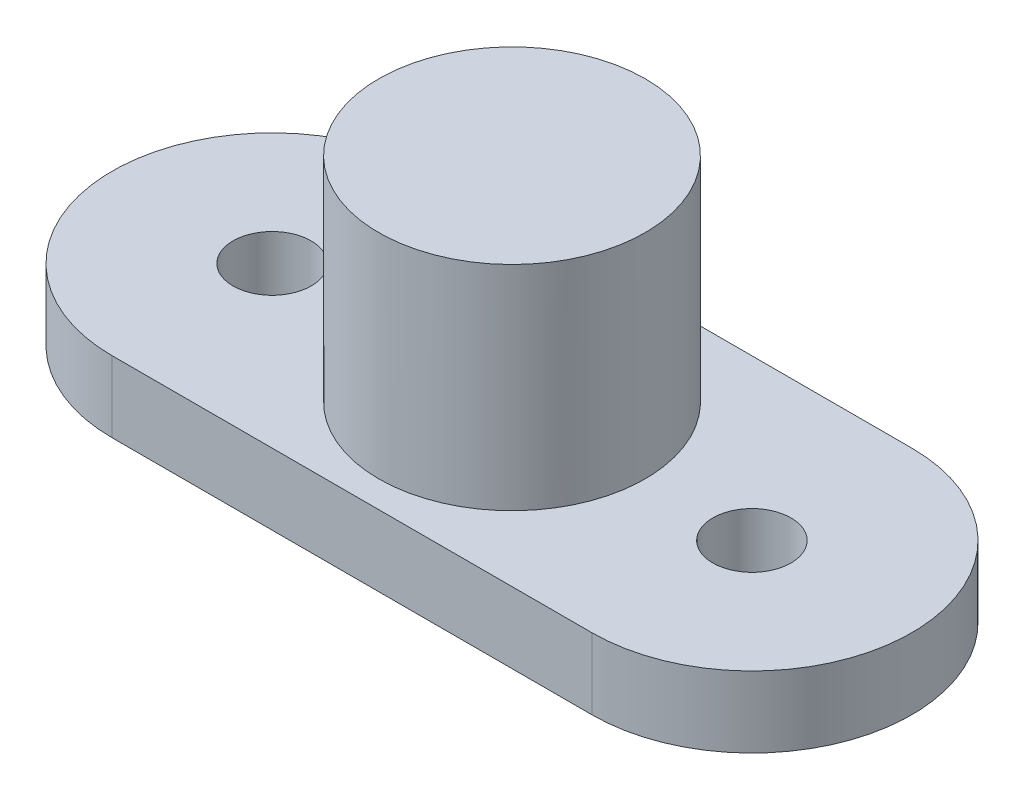
from build123d import *

# Parameters (mm, degrees)
SKETCH1_R           = 1.1
SKETCH1_R_2         = 3.75
BOSS_EXTRUDE3_DEPTH = 2
SKETCH3_R           = 3.75
BOSS_EXTRUDE4_DEPTH = 8


with BuildPart() as part:
    # Sketch1 → Boss-Extrude3 (new body)
    with BuildSketch(Plane(origin=(0, 0, 0), x_dir=(1, 0, 0), z_dir=(0, 1, 0))):
        with BuildLine():
            Line((-6.75, 4.499502967), (6.75, 4.499502967))
            ThreePointArc((6.75, 4.499502967), (11.249502967, 0), (6.75, -4.499502967))
            Line((6.75, -4.499502967), (-6.75, -4.499502967))
            ThreePointArc((-6.75, -4.499502967), (-11.249502967, 0), (-6.75, 4.499502967))
        make_face()
        with Locations((-6.75, 0)):
            Circle(SKETCH1_R, mode=Mode.SUBTRACT)
        with Locations((6.75, 0)):
            Circle(SKETCH1_R, mode=Mode.SUBTRACT)
        Circle(SKETCH1_R_2, mode=Mode.SUBTRACT)
    extrude(amount=BOSS_EXTRUDE3_DEPTH)

    # Sketch3 → Boss-Extrude4 (add)
    with BuildSketch(Plane.XZ):
        Circle(SKETCH3_R)
    extrude(amount=-BOSS_EXTRUDE4_DEPTH)


solid = part.part
